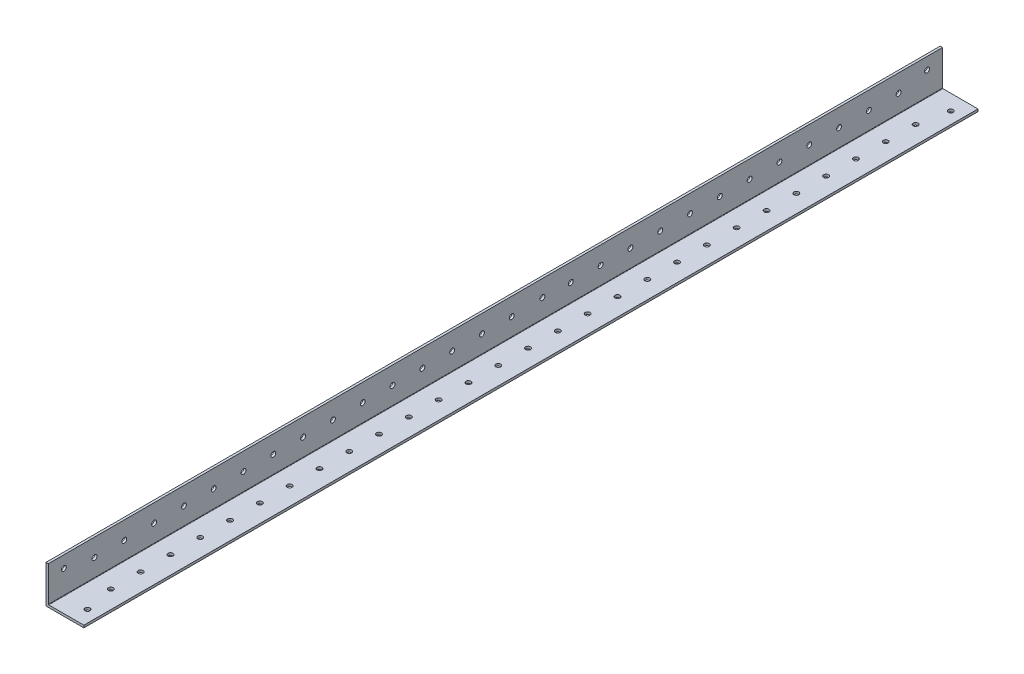
from build123d import *

# Parameters (mm, degrees)
BOSS_EXTRUDE1_DEPTH = 1219.2
FILLET1_R           = 0.254
SKETCH4_W           = 1838.4
SKETCH4_H           = 74.945320812
CUT_EXTRUDE1_DEPTH  = 60
SKETCH5_R           = 1.65
CUT_EXTRUDE2_DEPTH  = 10
SKETCH9_R           = 1.65
CUT_EXTRUDE6_DEPTH  = 60


with BuildPart() as part:
    # Sketch3 → Boss-Extrude1 (new, symmetric)
    with BuildSketch(Plane.XY):
        Polygon((1.5875, 25.4), (0, 25.4), (0, 0), (25.4, 0), (25.4, 1.5875), (1.5875, 1.5875), align=None)
    extrude(amount=BOSS_EXTRUDE1_DEPTH, both=True)

    # Fillet1
    fillet1_edges = [part.edges().sort_by_distance(p)[0] for p in [
        (1.5875, 1.5875, 0),
    ]]
    fillet(fillet1_edges, radius=FILLET1_R)

    # Sketch4 → Cut-Extrude1 (cut)
    with BuildSketch(Plane.ZY):
        with Locations((-300, 37.472660406)):
            Rectangle(SKETCH4_W, SKETCH4_H)
    extrude(amount=-CUT_EXTRUDE1_DEPTH, mode=Mode.SUBTRACT)

    # Sketch5 → Cut-Extrude2 (cut)
    with BuildSketch(Plane(origin=(0, 1.5875, 0), x_dir=(1, 0, 0), z_dir=(0, 1, 0))):
        with Locations(Location((17.4625, -629.5759, 0), (0, 0, 180))):
            Circle(SKETCH5_R)
        with Locations(Location((17.4625, -1208.8241, 0), (0, 0, 180))):
            Circle(SKETCH5_R)
        with Locations(Location((13.49375, -1189.2, 0), (0, 0, 180))):
            Circle(SKETCH5_R)
        with Locations(Location((13.49375, -1169.2, 0), (0, 0, 180))):
            Circle(SKETCH5_R)
        with Locations(Location((13.49375, -1149.2, 0), (0, 0, 180))):
            Circle(SKETCH5_R)
        with Locations(Location((13.49375, -1129.2, 0), (0, 0, 180))):
            Circle(SKETCH5_R)
        with Locations(Location((13.49375, -1109.2, 0), (0, 0, 180))):
            Circle(SKETCH5_R)
        with Locations(Location((13.49375, -1089.2, 0), (0, 0, 180))):
            Circle(SKETCH5_R)
        with Locations(Location((13.49375, -1069.2, 0), (0, 0, 180))):
            Circle(SKETCH5_R)
        with Locations(Location((13.49375, -1049.2, 0), (0, 0, 180))):
            Circle(SKETCH5_R)
        with Locations(Location((13.49375, -1029.2, 0), (0, 0, 180))):
            Circle(SKETCH5_R)
        with Locations(Location((13.49375, -1009.2, 0), (0, 0, 180))):
            Circle(SKETCH5_R)
        with Locations(Location((13.49375, -989.2, 0), (0, 0, 180))):
            Circle(SKETCH5_R)
        with Locations(Location((13.49375, -969.2, 0), (0, 0, 180))):
            Circle(SKETCH5_R)
        with Locations(Location((13.49375, -949.2, 0), (0, 0, 180))):
            Circle(SKETCH5_R)
        with Locations(Location((13.49375, -929.2, 0), (0, 0, 180))):
            Circle(SKETCH5_R)
        with Locations(Location((13.49375, -909.2, 0), (0, 0, 180))):
            Circle(SKETCH5_R)
        with Locations(Location((13.49375, -889.2, 0), (0, 0, 180))):
            Circle(SKETCH5_R)
        with Locations(Location((13.49375, -869.2, 0), (0, 0, 180))):
            Circle(SKETCH5_R)
        with Locations(Location((13.49375, -849.2, 0), (0, 0, 180))):
            Circle(SKETCH5_R)
        with Locations(Location((13.49375, -829.2, 0), (0, 0, 180))):
            Circle(SKETCH5_R)
        with Locations(Location((13.49375, -809.2, 0), (0, 0, 180))):
            Circle(SKETCH5_R)
        with Locations(Location((13.49375, -789.2, 0), (0, 0, 180))):
            Circle(SKETCH5_R)
        with Locations(Location((13.49375, -769.2, 0), (0, 0, 180))):
            Circle(SKETCH5_R)
        with Locations(Location((13.49375, -749.2, 0), (0, 0, 180))):
            Circle(SKETCH5_R)
        with Locations(Location((13.49375, -729.2, 0), (0, 0, 180))):
            Circle(SKETCH5_R)
        with Locations(Location((13.49375, -709.2, 0), (0, 0, 180))):
            Circle(SKETCH5_R)
        with Locations(Location((13.49375, -689.2, 0), (0, 0, 180))):
            Circle(SKETCH5_R)
        with Locations(Location((13.49375, -669.2, 0), (0, 0, 180))):
            Circle(SKETCH5_R)
        with Locations(Location((13.49375, -649.2, 0), (0, 0, 180))):
            Circle(SKETCH5_R)
    extrude(amount=-CUT_EXTRUDE2_DEPTH, mode=Mode.SUBTRACT)

    # Sketch9 → Cut-Extrude6 (cut)
    with BuildSketch(Plane(origin=(1.5875, 0, 0), x_dir=(0, 0, -1), z_dir=(1, 0, 0))):
        with Locations((-629.5759, 17.4625)):
            Circle(SKETCH9_R)
        with Locations((-648.634825, 13.49375)):
            Circle(SKETCH9_R)
        with Locations((-887.69375, 14.2875)):
            Circle(SKETCH9_R)
        with Locations((-1208.8241, 17.463)):
            Circle(SKETCH9_R)
        with Locations((-668.634825, 13.49375)):
            Circle(SKETCH9_R)
        with Locations((-688.634825, 13.49375)):
            Circle(SKETCH9_R)
        with Locations((-708.634825, 13.49375)):
            Circle(SKETCH9_R)
        with Locations((-728.634825, 13.49375)):
            Circle(SKETCH9_R)
        with Locations((-748.634825, 13.49375)):
            Circle(SKETCH9_R)
        with Locations((-768.634825, 13.49375)):
            Circle(SKETCH9_R)
        with Locations((-788.634825, 13.49375)):
            Circle(SKETCH9_R)
        with Locations((-808.634825, 13.49375)):
            Circle(SKETCH9_R)
        with Locations((-828.634825, 13.49375)):
            Circle(SKETCH9_R)
        with Locations((-848.634825, 13.49375)):
            Circle(SKETCH9_R)
        with Locations((-868.634825, 13.49375)):
            Circle(SKETCH9_R)
        with Locations((-908.258925, 13.49375)):
            Circle(SKETCH9_R)
        with Locations((-928.258925, 13.49375)):
            Circle(SKETCH9_R)
        with Locations((-948.258925, 13.49375)):
            Circle(SKETCH9_R)
        with Locations((-968.258925, 13.49375)):
            Circle(SKETCH9_R)
        with Locations((-988.258925, 13.49375)):
            Circle(SKETCH9_R)
        with Locations((-1008.258925, 13.49375)):
            Circle(SKETCH9_R)
        with Locations((-1028.258925, 13.49375)):
            Circle(SKETCH9_R)
        with Locations((-1048.258925, 13.49375)):
            Circle(SKETCH9_R)
        with Locations((-1068.258925, 13.49375)):
            Circle(SKETCH9_R)
        with Locations((-1088.258925, 13.49375)):
            Circle(SKETCH9_R)
        with Locations((-1108.258925, 13.49375)):
            Circle(SKETCH9_R)
        with Locations((-1128.258925, 13.49375)):
            Circle(SKETCH9_R)
        with Locations((-1148.258925, 13.49375)):
            Circle(SKETCH9_R)
        with Locations((-1168.258925, 13.49375)):
            Circle(SKETCH9_R)
        with Locations((-1188.258925, 13.49375)):
            Circle(SKETCH9_R)
    extrude(amount=-CUT_EXTRUDE6_DEPTH, mode=Mode.SUBTRACT)


solid = part.part
